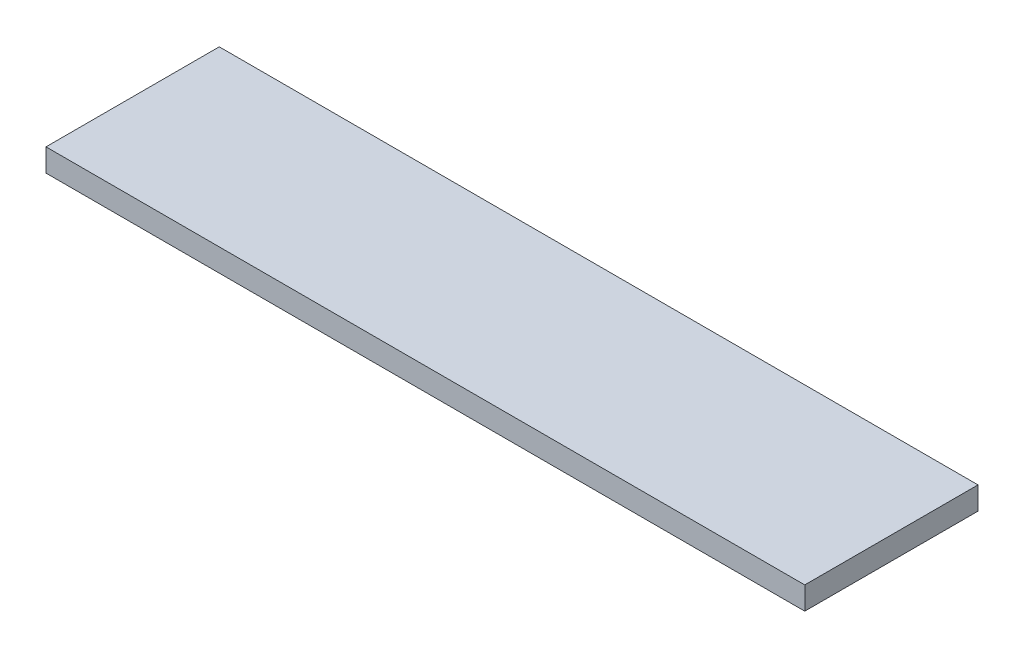
from build123d import *

# Parameters (mm, degrees)
SKETCH_1_W      = 600
SKETCH_1_H      = 137
EXTRUDE_1_DEPTH = 18


with BuildPart() as part:
    # Эскиз1 → Бобышка-Вытянуть1 (new body)
    with BuildSketch(Plane(origin=(0, 0, 0), x_dir=(1, 0, 0), z_dir=(0, 1, 0))):
        Rectangle(SKETCH_1_W, SKETCH_1_H)
    extrude(amount=EXTRUDE_1_DEPTH)


solid = part.part
